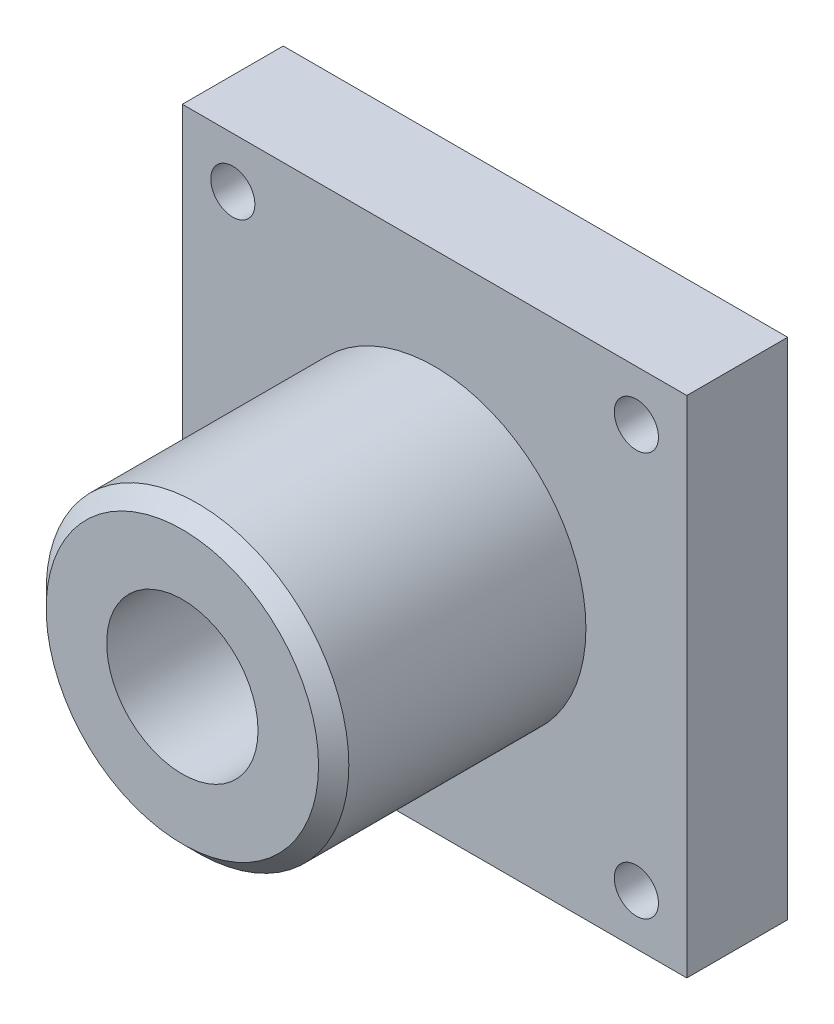
from build123d import *

# Parameters (mm, degrees)
SKETCH1_W                    = 254
SKETCH1_H                    = 254
BOSS_EXTRUDE1_DEPTH          = 50.8
SKETCH2_R                    = 76.2
BOSS_EXTRUDE2_DEPTH          = 127
CHAMFER1_SIZE                = 7.62
SKETCH3_R                    = 38.1
CUT_EXTRUDE1_DEPTH           = 178.8
F_7_8_0_875_DIAMETER_HOLE1_D = 22.225


with BuildPart() as part:
    # Sketch1 → Boss-Extrude1 (new body)
    with BuildSketch(Plane.XY):
        Rectangle(SKETCH1_W, SKETCH1_H)
    extrude(amount=BOSS_EXTRUDE1_DEPTH)

    # Sketch2 → Boss-Extrude2 (add)
    with BuildSketch(Plane.XY.offset(50.8)):
        Circle(SKETCH2_R)
    extrude(amount=BOSS_EXTRUDE2_DEPTH)

    # Chamfer1
    chamfer1_edges = [part.edges().sort_by_distance(p)[0] for p in [
        (-76.2, 0, 177.8),
    ]]
    chamfer(chamfer1_edges, length=CHAMFER1_SIZE)

    # Sketch3 → Cut-Extrude1 (cut, through all)
    with BuildSketch(Plane.XY.offset(177.8)):
        Circle(SKETCH3_R)
    extrude(amount=-CUT_EXTRUDE1_DEPTH, mode=Mode.SUBTRACT)

    # 7/8 (0.875) Diameter Hole1 (through all)
    with Locations(Plane.XY.offset(50.8)):
        with Locations((-101.6, 101.6), (101.6, 101.6), (101.6, -101.6), (-101.6, -101.6)):
            Hole(F_7_8_0_875_DIAMETER_HOLE1_D / 2)


solid = part.part
